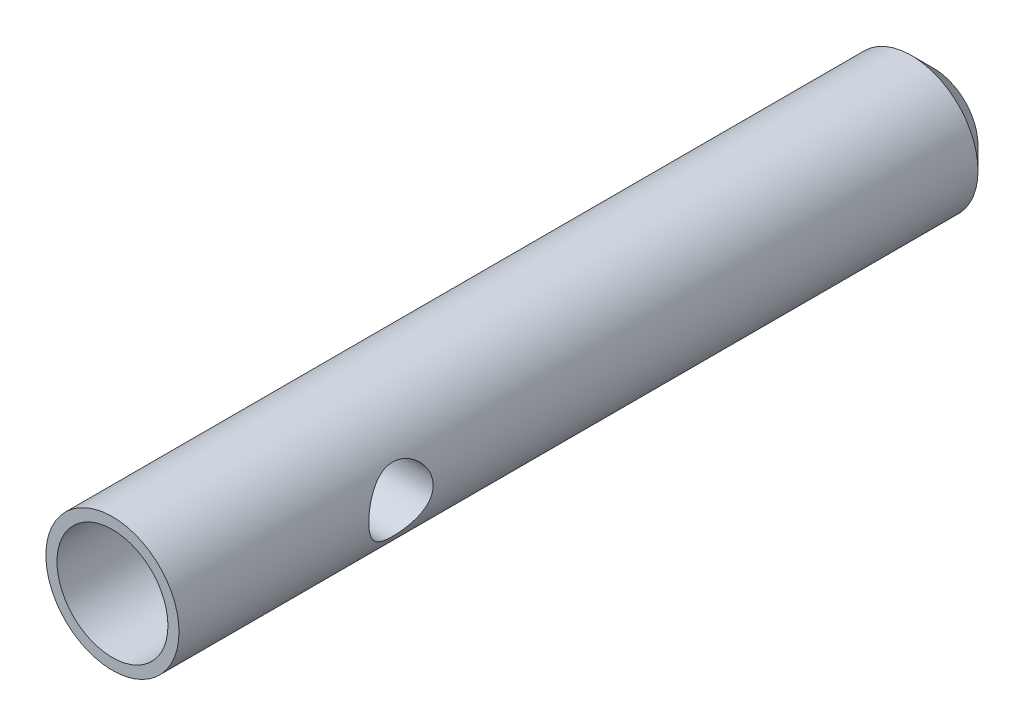
from build123d import *

# Parameters (mm, degrees)
SKETCH_1_R          = 3
EXTRUDE_1_DEPTH     = 37
SKETCH_2_R          = 2.5
CUT_EXTRUDE_1_DEPTH = 6
CHAMFER_1_SIZE      = 1
M3_5X0_61_D         = 2.9


with BuildPart() as part:
    # Эскиз1 → Бобышка-Вытянуть1 (new body)
    with BuildSketch(Plane.XY):
        Circle(SKETCH_1_R)
    extrude(amount=EXTRUDE_1_DEPTH)

    # Эскиз2 → Вырез-Вытянуть1 (cut)
    with BuildSketch(Plane.XY.offset(37)):
        Circle(SKETCH_2_R)
    extrude(amount=-CUT_EXTRUDE_1_DEPTH, mode=Mode.SUBTRACT)

    # Фаска1
    chamfer_1_edges = [part.edges().sort_by_distance(p)[0] for p in [
        (-3, 0, 0),
    ]]
    chamfer(chamfer_1_edges, length=CHAMFER_1_SIZE)

    # Отверстие обработанное метчиком M3.5x0.61 (through all)
    with Locations(Plane(origin=(3, 0, 0), x_dir=(0, 0, -1), z_dir=(1, 0, 0))):
        with Locations((-27, 0)):
            Hole(M3_5X0_61_D / 2)


solid = part.part
